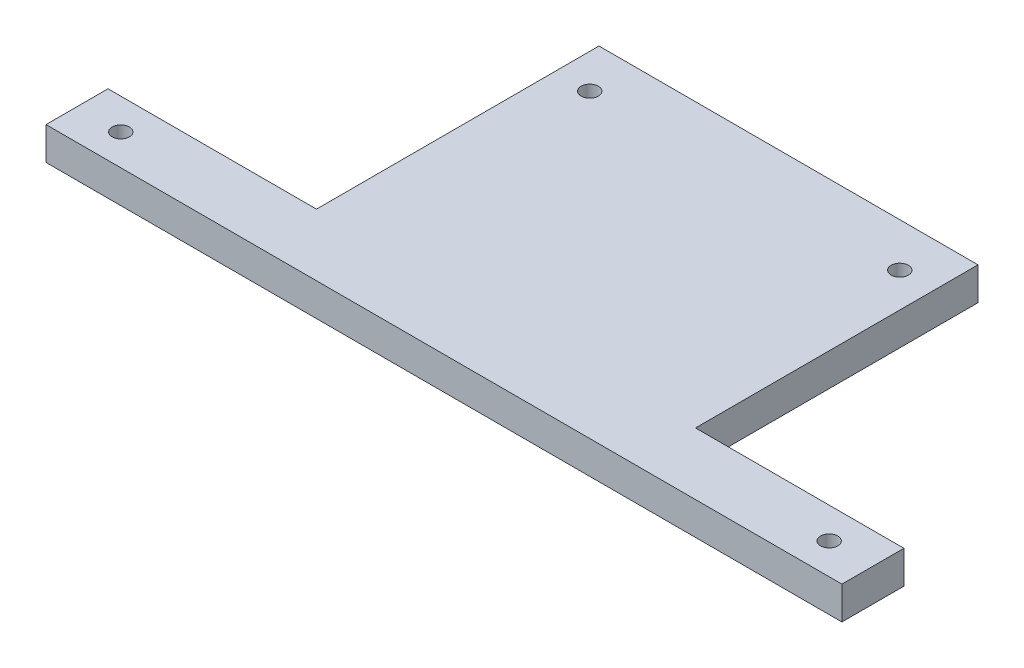
from build123d import *

# Parameters (mm, degrees)
BOSS_EXTRUDE1_DEPTH             = 4.7625
TAP_DRILL_FOR_M6X1_0_TAP1_D     = 5
TAP_DRILL_FOR_M6X1_0_TAP1_DEPTH = 9.525


with BuildPart() as part:
    # Sketch1 → Boss-Extrude1 (new body, symmetric)
    with BuildSketch(Plane(origin=(0, 0, 0), x_dir=(1, 0, 0), z_dir=(0, 1, 0))):
        Polygon((-55, -1), (-55, 81), (55, 81), (55, -1), (115.5, -1), (115.5, -19), (-115.5, -19), (-115.5, -1), align=None)
    extrude(amount=BOSS_EXTRUDE1_DEPTH, both=True)

    # Tap Drill for M6x1.0 Tap1
    with Locations(Plane(origin=(0, 4.7625, 0), x_dir=(1, 0, 0), z_dir=(0, 1, 0))):
        with Locations((-45, 68.3), (45, 68.3), (-102.8, -10), (102.8, -10)):
            Hole(TAP_DRILL_FOR_M6X1_0_TAP1_D / 2, depth=TAP_DRILL_FOR_M6X1_0_TAP1_DEPTH)


solid = part.part
